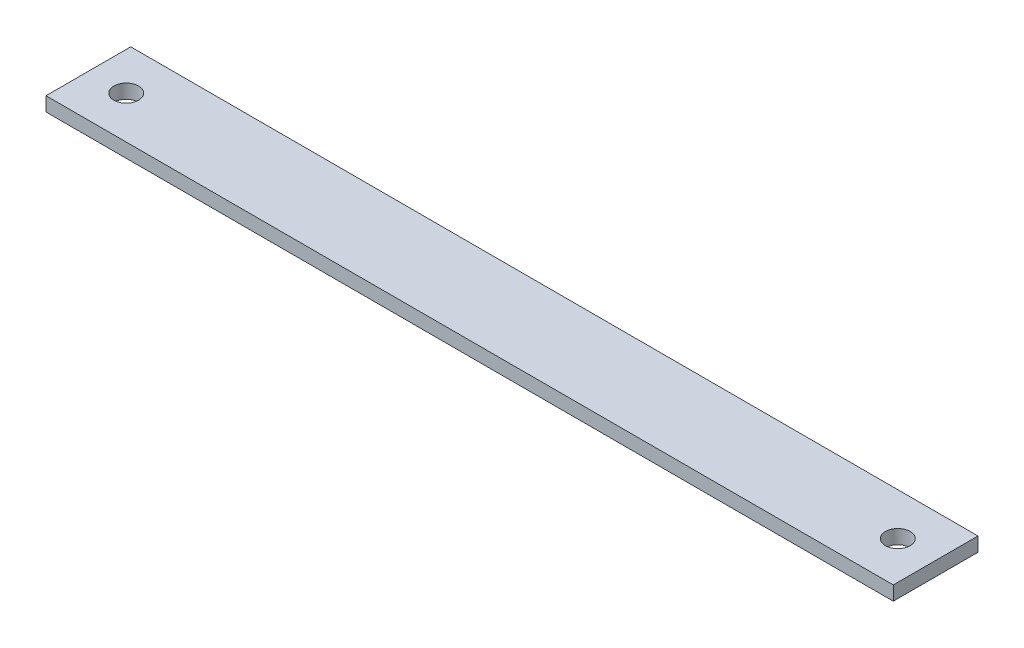
from build123d import *

# Parameters (mm, degrees)
SKETCH1_W           = 762
SKETCH1_H           = 76.2
BOSS_EXTRUDE1_DEPTH = 12.7
SKETCH4_R           = 11.1125
CUT_EXTRUDE1_DEPTH  = 13.7


with BuildPart() as part:
    # Sketch1 → Boss-Extrude1 (new body)
    with BuildSketch(Plane(origin=(0, 0, 0), x_dir=(1, 0, 0), z_dir=(0, 1, 0))):
        with Locations((324.729216151, 22.864711876)):
            Rectangle(SKETCH1_W, SKETCH1_H)
    extrude(amount=BOSS_EXTRUDE1_DEPTH)

    # Sketch4 → Cut-Extrude1 (cut, through all)
    with BuildSketch(Plane(origin=(0, 12.7, 0), x_dir=(1, 0, 0), z_dir=(0, 1, 0))):
        with Locations((671.693216151, 22.864711876)):
            Circle(SKETCH4_R)
        with Locations((-22.234783849, 22.864711876)):
            Circle(SKETCH4_R)
    extrude(amount=-CUT_EXTRUDE1_DEPTH, mode=Mode.SUBTRACT)


solid = part.part
